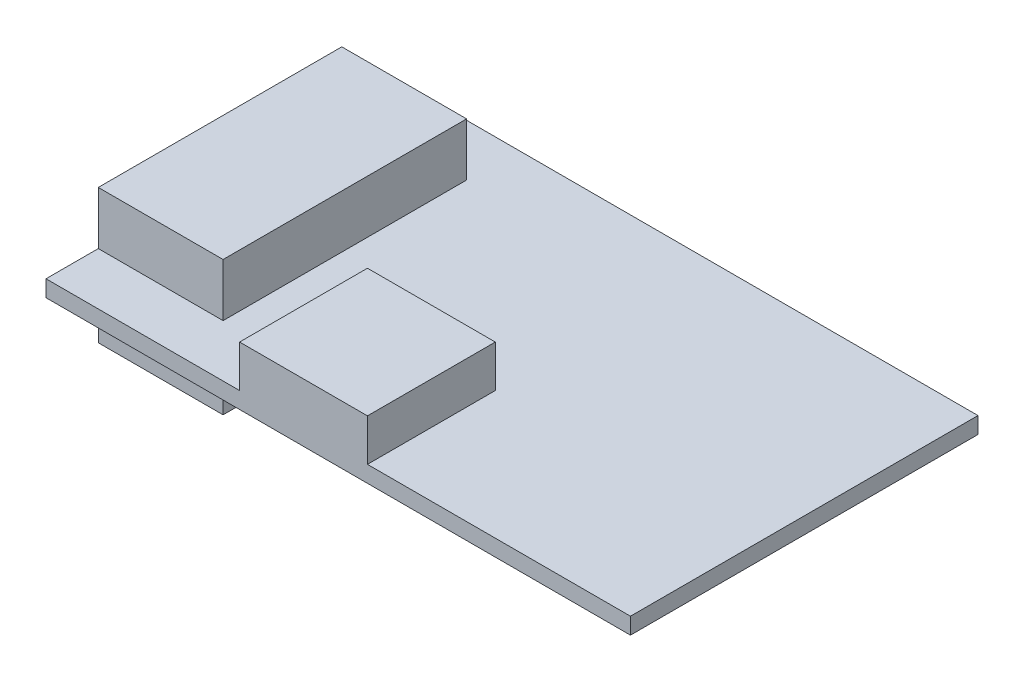
from build123d import *

# Parameters (mm, degrees)
SKETCH1_W           = 24.384
SKETCH1_H           = 14.5
BOSS_EXTRUDE1_DEPTH = 0.6858
SKETCH2_W           = 5.207
SKETCH2_H           = 10.16
BOSS_EXTRUDE2_DEPTH = 2.2098
SKETCH3_W           = 5.207
SKETCH3_H           = 10.16
BOSS_EXTRUDE3_DEPTH = 2.7178
SKETCH4_W           = 5.334
SKETCH4_H           = 5.334
BOSS_EXTRUDE4_DEPTH = 1.7526


with BuildPart() as part:
    # Sketch1 → Boss-Extrude1 (new body)
    with BuildSketch(Plane(origin=(0, 0, 0), x_dir=(1, 0, 0), z_dir=(0, 1, 0))):
        with Locations((12.192, 7.25)):
            Rectangle(SKETCH1_W, SKETCH1_H)
    extrude(amount=BOSS_EXTRUDE1_DEPTH)

    # Sketch2 → Boss-Extrude2 (add)
    with BuildSketch(Plane(origin=(0, 0.6858, 0), x_dir=(1, 0, 0), z_dir=(0, 1, 0))):
        with Locations((2.6035, 7.261)):
            Rectangle(SKETCH2_W, SKETCH2_H)
    extrude(amount=BOSS_EXTRUDE2_DEPTH)

    # Sketch3 → Boss-Extrude3 (add)
    with BuildSketch(Plane.XZ):
        with Locations((2.6035, -7.261)):
            Rectangle(SKETCH3_W, SKETCH3_H)
    extrude(amount=BOSS_EXTRUDE3_DEPTH)

    # Sketch4 → Boss-Extrude4 (add)
    with BuildSketch(Plane(origin=(0, 0.6858, 0), x_dir=(1, 0, 0), z_dir=(0, 1, 0))):
        with Locations((10.7442, 2.667)):
            Rectangle(SKETCH4_W, SKETCH4_H)
    extrude(amount=BOSS_EXTRUDE4_DEPTH)


solid = part.part
